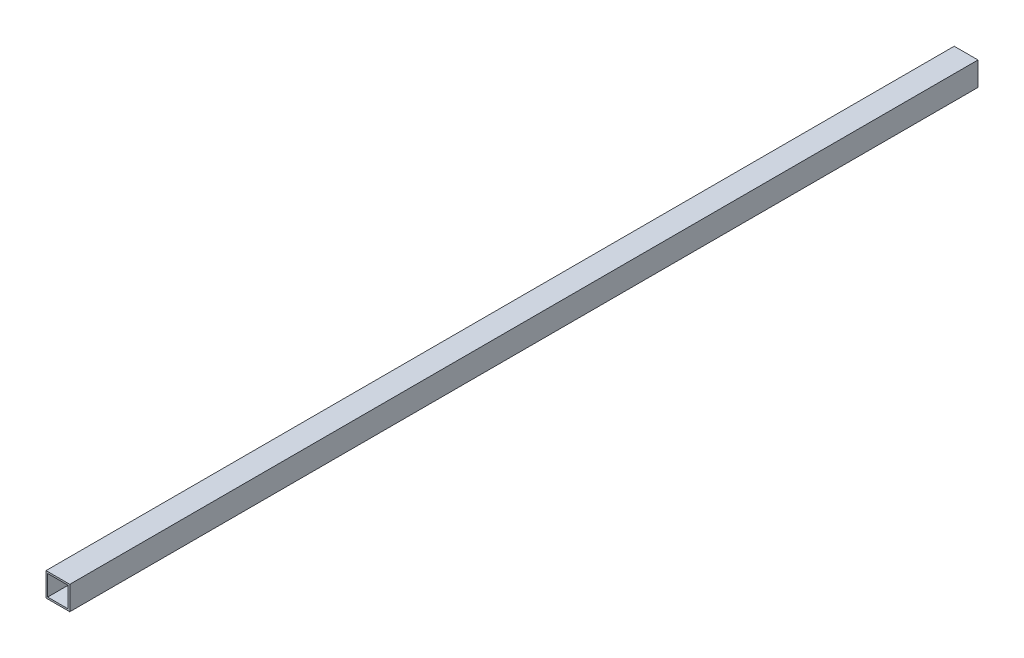
from build123d import *

# Parameters (mm, degrees)
SKETCH1_W           = 17
SKETCH1_H           = 17
SKETCH1_W_2         = 14.6
SKETCH1_H_2         = 14.6
BOSS_EXTRUDE1_DEPTH = 649


with BuildPart() as part:
    # Sketch1 → Boss-Extrude1 (new body)
    with BuildSketch(Plane.XY):
        Rectangle(SKETCH1_W, SKETCH1_H)
        Rectangle(SKETCH1_W_2, SKETCH1_H_2, mode=Mode.SUBTRACT)
    extrude(amount=BOSS_EXTRUDE1_DEPTH)


solid = part.part
